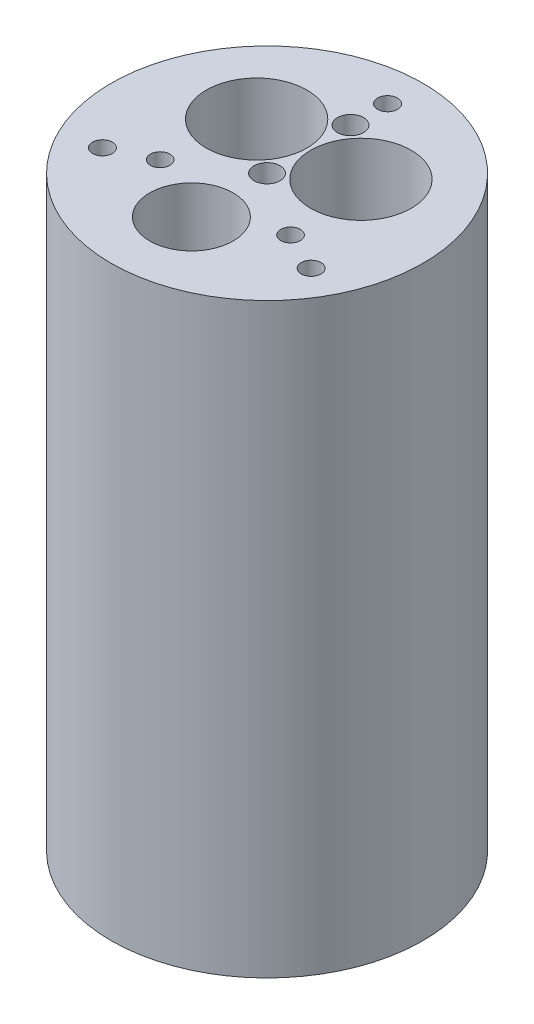
from build123d import *

# Parameters (mm, degrees)
SKETCH1_R               = 37.973
BOSS_EXTRUDE1_DEPTH     = 142.8496
SKETCH2_R               = 2.413
CUT_EXTRUDE1_DEPTH      = 153.610306592
SKETCH3_R               = 12.2555
CUT_EXTRUDE2_DEPTH      = 153.610306592
SKETCH4_R               = 3.175
CUT_EXTRUDE3_DEPTH      = 6.35
SKETCH5_R               = 10.16
CUT_EXTRUDE4_DEPTH      = 17.78
CUT_EXTRUDE5_DEPTH      = 153.610306592
CUT_EXTRUDE5_DEPTH_BACK = 153.610306592
SKETCH6_R               = 2.38125


with BuildPart() as part:
    # Sketch1 → Boss-Extrude1 (new body)
    with BuildSketch(Plane(origin=(0, 0, 0), x_dir=(1, 0, 0), z_dir=(0, 1, 0))):
        Circle(SKETCH1_R)
    extrude(amount=BOSS_EXTRUDE1_DEPTH)

    # Sketch2 → Cut-Extrude1 (cut, through all)
    with BuildSketch(Plane(origin=(0, 142.8496, 0), x_dir=(1, 0, 0), z_dir=(0, 1, 0))):
        with Locations((0, 29.337)):
            Circle(SKETCH2_R)
        with Locations((25.406587271, -14.6685)):
            Circle(SKETCH2_R)
        with Locations((-25.406587271, -14.6685)):
            Circle(SKETCH2_R)
    extrude(amount=-CUT_EXTRUDE1_DEPTH, mode=Mode.SUBTRACT)

    # Sketch3 → Cut-Extrude2 (cut, through all)
    with BuildSketch(Plane(origin=(0, 142.8496, 0), x_dir=(1, 0, 0), z_dir=(0, 1, 0))):
        with Locations((-12.7, 10.16)):
            Circle(SKETCH3_R)
        with Locations((12.7, 10.16)):
            Circle(SKETCH3_R)
    extrude(amount=-CUT_EXTRUDE2_DEPTH, mode=Mode.SUBTRACT)

    # Sketch4 → Cut-Extrude3 (cut)
    with BuildSketch(Plane(origin=(0, 142.8496, 0), x_dir=(1, 0, 0), z_dir=(0, 1, 0))):
        with Locations((0, 20.32)):
            Circle(SKETCH4_R)
        Circle(SKETCH4_R)
    extrude(amount=-CUT_EXTRUDE3_DEPTH, mode=Mode.SUBTRACT)

    # Sketch5 → Cut-Extrude4 (cut)
    with BuildSketch(Plane(origin=(0, 142.8496, 0), x_dir=(1, 0, 0), z_dir=(0, 1, 0))):
        with Locations((0, -18.415)):
            Circle(SKETCH5_R)
    extrude(amount=-CUT_EXTRUDE4_DEPTH, mode=Mode.SUBTRACT)

    # Sketch6 → Cut-Extrude5 (cut, two sides: drawn at the far end of the back side and taken through both)
    with BuildSketch(Plane(origin=(0, 142.8496, 0), x_dir=(1, 0, 0), z_dir=(0, 1, 0)).offset(-CUT_EXTRUDE5_DEPTH_BACK)):
        with Locations((15.875, -10.16)):
            Circle(SKETCH6_R)
        with Locations((-15.875, -10.16)):
            Circle(SKETCH6_R)
    extrude(amount=CUT_EXTRUDE5_DEPTH + CUT_EXTRUDE5_DEPTH_BACK, mode=Mode.SUBTRACT)


solid = part.part
